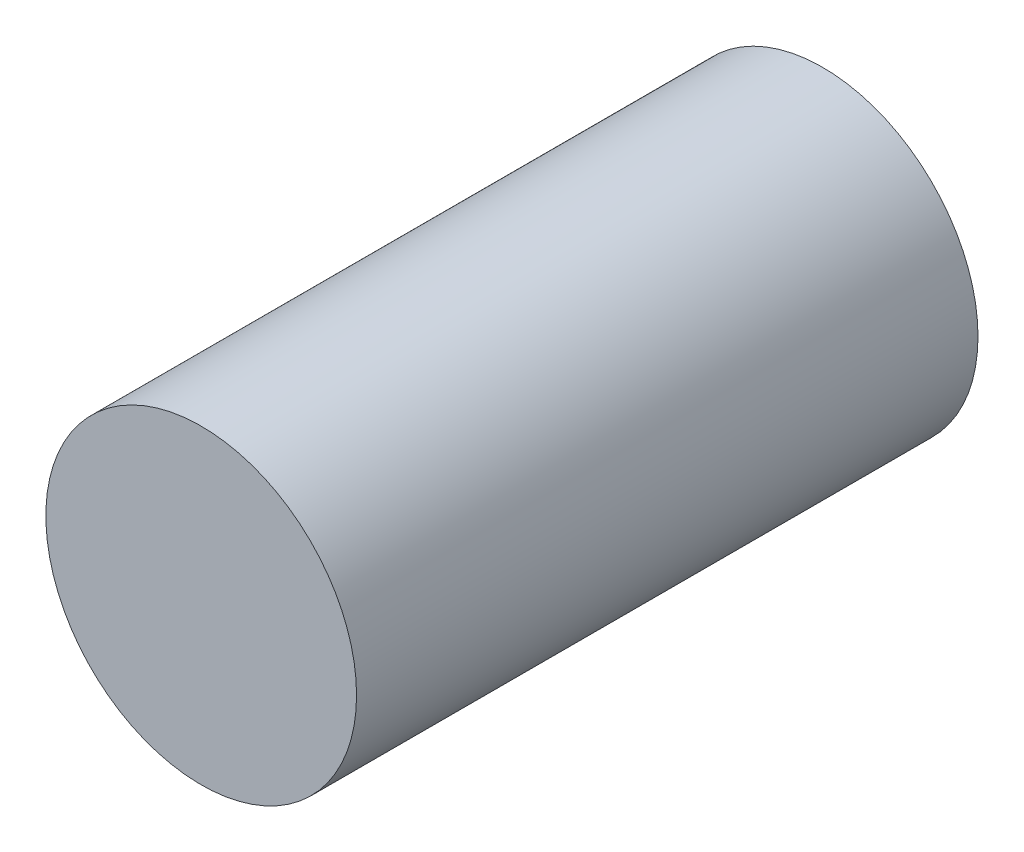
from build123d import *

# Parameters (mm, degrees)
SKETCH1_R           = 15
BOSS_EXTRUDE1_DEPTH = 60


with BuildPart() as part:
    # Sketch1 → Boss-Extrude1 (new body)
    with BuildSketch(Plane.XY):
        Circle(SKETCH1_R)
    extrude(amount=BOSS_EXTRUDE1_DEPTH)


solid = part.part
